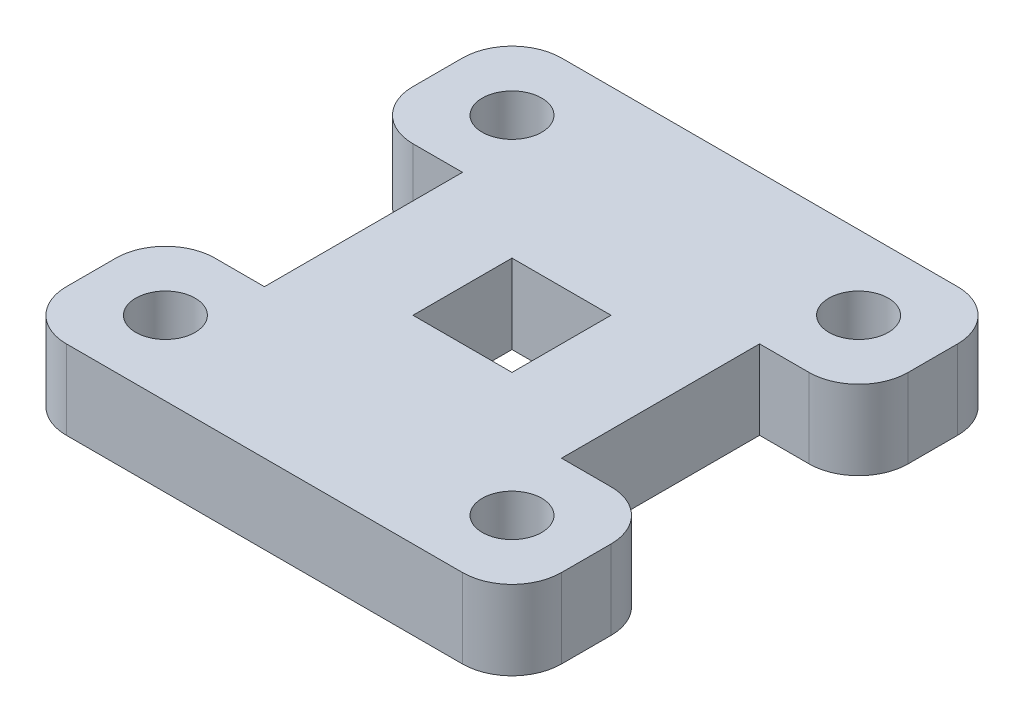
from build123d import *

# Parameters (mm, degrees)
SKETCH1_R           = 6
SKETCH1_W           = 20
SKETCH1_H           = 20
BOSS_EXTRUDE1_DEPTH = 16


with BuildPart() as part:
    # Sketch1 → Boss-Extrude1 (new body)
    with BuildSketch(Plane(origin=(0, 0, 0), x_dir=(1, 0, 0), z_dir=(0, 1, 0))):
        with BuildLine():
            Line((-40, 50), (40, 50))
            ThreePointArc((40, 50), (47.071067812, 47.071067812), (50, 40))
            Line((50, 40), (50, 30))
            ThreePointArc((50, 30), (47.071067812, 22.928932188), (40, 20))
            Line((40, 20), (30, 20))
            Line((30, 20), (30, -20))
            Line((30, -20), (40, -20))
            ThreePointArc((40, -20), (47.071067812, -22.928932188), (50, -30))
            Line((50, -30), (50, -40))
            ThreePointArc((50, -40), (47.071067812, -47.071067812), (40, -50))
            Line((40, -50), (-40, -50))
            ThreePointArc((-40, -50), (-47.071067812, -47.071067812), (-50, -40))
            Line((-50, -40), (-50, -30))
            ThreePointArc((-50, -30), (-47.071067812, -22.928932188), (-40, -20))
            Line((-40, -20), (-30, -20))
            Line((-30, -20), (-30, 20))
            Line((-30, 20), (-40, 20))
            ThreePointArc((-40, 20), (-47.071067812, 22.928932188), (-50, 30))
            Line((-50, 30), (-50, 40))
            ThreePointArc((-50, 40), (-47.071067812, 47.071067812), (-40, 50))
        make_face()
        with Locations((35, 35)):
            Circle(SKETCH1_R, mode=Mode.SUBTRACT)
        with Locations((35, -35)):
            Circle(SKETCH1_R, mode=Mode.SUBTRACT)
        with Locations((-35, -35)):
            Circle(SKETCH1_R, mode=Mode.SUBTRACT)
        with Locations((-35, 35)):
            Circle(SKETCH1_R, mode=Mode.SUBTRACT)
        Rectangle(SKETCH1_W, SKETCH1_H, mode=Mode.SUBTRACT)
    extrude(amount=BOSS_EXTRUDE1_DEPTH)


solid = part.part
